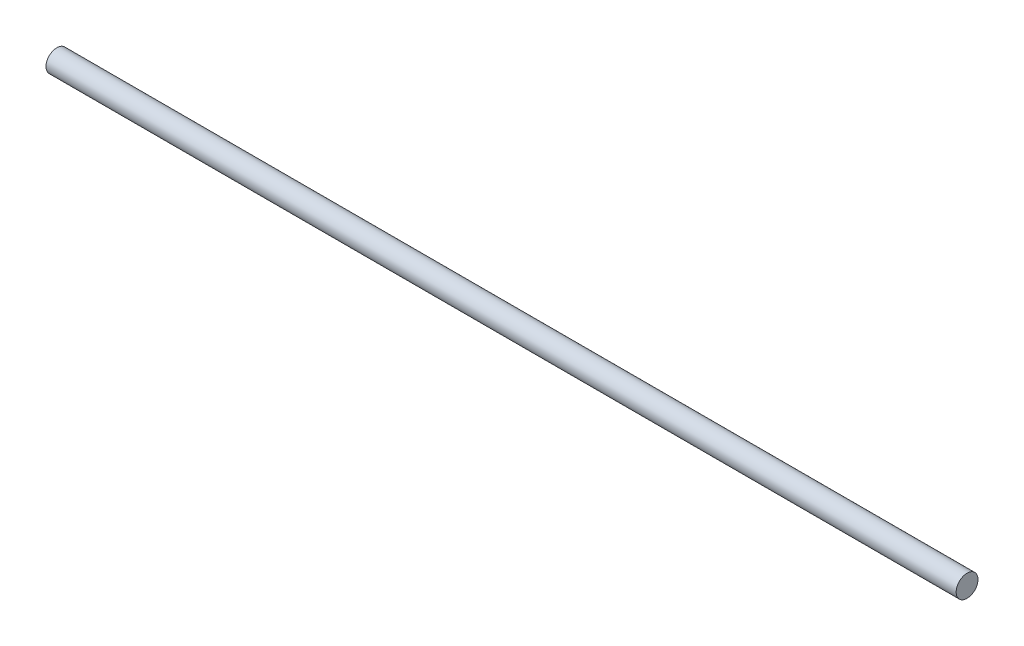
from build123d import *

# Parameters (mm, degrees)
ESBO_O1_R                = 3
RESSALTO_EXTRUS_O1_DEPTH = 250


with BuildPart() as part:
    # Esboço1 → Ressalto-extrusão1 (new body)
    with BuildSketch(Plane(origin=(0, 0, 0), x_dir=(0, 0, -1), z_dir=(1, 0, 0))):
        Circle(ESBO_O1_R)
    extrude(amount=RESSALTO_EXTRUS_O1_DEPTH)


solid = part.part
